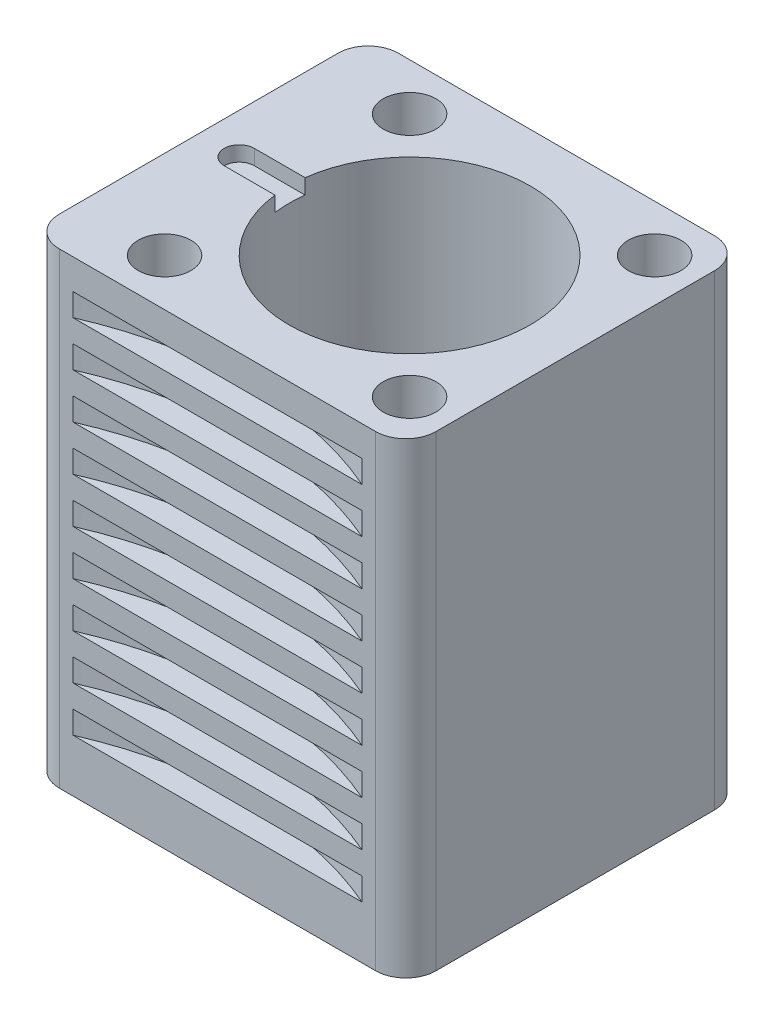
from build123d import *

# Parameters (mm, degrees)
BOSS_EXTRUDE1_DEPTH     = 62
SKETCH2_R               = 18
BOSS_EXTRUDE2_DEPTH     = 2
SKETCH3_R               = 16
CUT_EXTRUDE1_DEPTH      = 65
CUT_EXTRUDE2_DEPTH      = 2
SKETCH6_R               = 3.5
CUT_EXTRUDE3_DEPTH      = 65
SKETCH7_W               = 48
SKETCH7_H               = 3
LPATTERN1_COUNT         = 9
LPATTERN1_PITCH         = 6
MIRROR1_COPY_1_SKETCH_W = 48
MIRROR1_COPY_1_SKETCH_H = 3
MIRROR1_COPY_2_SKETCH_W = 48
MIRROR1_COPY_2_SKETCH_H = 3
MIRROR1_COPY_3_SKETCH_W = 48
MIRROR1_COPY_3_SKETCH_H = 3
MIRROR1_COPY_4_SKETCH_W = 48
MIRROR1_COPY_4_SKETCH_H = 3
MIRROR1_COPY_5_SKETCH_W = 48
MIRROR1_COPY_5_SKETCH_H = 3
MIRROR1_COPY_6_SKETCH_W = 48
MIRROR1_COPY_6_SKETCH_H = 3
MIRROR1_COPY_7_SKETCH_W = 48
MIRROR1_COPY_7_SKETCH_H = 3
MIRROR1_COPY_8_SKETCH_W = 48
MIRROR1_COPY_8_SKETCH_H = 3
SKETCH9_W               = 48
SKETCH9_H               = 3
LPATTERN2_COUNT         = 9
LPATTERN2_PITCH         = 6


with BuildPart() as part:
    # Sketch1 → Boss-Extrude1 (new body)
    with BuildSketch(Plane(origin=(0, 0, 0), x_dir=(1, 0, 0), z_dir=(0, 1, 0))):
        with BuildLine():
            Line((-24, 22.5), (18, 22.5))
            ThreePointArc((18, 22.5), (20.828427125, 21.328427125), (22, 18.5))
            Line((22, 18.5), (22, -18.5))
            ThreePointArc((22, -18.5), (20.828427125, -21.328427125), (18, -22.5))
            Line((18, -22.5), (-24, -22.5))
            ThreePointArc((-24, -22.5), (-26.828427125, -21.328427125), (-28, -18.5))
            Line((-28, -18.5), (-28, 18.5))
            ThreePointArc((-28, 18.5), (-26.828427125, 21.328427125), (-24, 22.5))
        make_face()
    extrude(amount=BOSS_EXTRUDE1_DEPTH)

    # Sketch2 → Boss-Extrude2 (add)
    with BuildSketch(Plane.XZ):
        Circle(SKETCH2_R)
    extrude(amount=BOSS_EXTRUDE2_DEPTH)

    # Sketch3 → Cut-Extrude1 (cut, through all)
    with BuildSketch(Plane.XZ.offset(2)):
        Circle(SKETCH3_R)
    extrude(amount=-CUT_EXTRUDE1_DEPTH, mode=Mode.SUBTRACT)

    # Sketch5 → Cut-Extrude2 (cut)
    with BuildSketch(Plane(origin=(0, 62, 0), x_dir=(1, 0, 0), z_dir=(0, 1, 0))):
        with BuildLine():
            Line((-22.61, 2), (-11.427293838, 2))
            Line((-11.427293838, 2), (-11.427293838, -2))
            Line((-11.427293838, -2), (-22.61, -2))
            ThreePointArc((-22.61, -2), (-24.61, 0), (-22.61, 2))
        make_face()
    extrude(amount=-CUT_EXTRUDE2_DEPTH, mode=Mode.SUBTRACT)

    # Sketch6 → Cut-Extrude3 (cut, through all)
    with BuildSketch(Plane(origin=(0, 62, 0), x_dir=(1, 0, 0), z_dir=(0, 1, 0))):
        with Locations((16.263455967, 16.263455967)):
            Circle(SKETCH6_R)
        with Locations((16.263455967, -16.263455967)):
            Circle(SKETCH6_R)
        with Locations((-16.263455967, -16.263455967)):
            Circle(SKETCH6_R)
        with Locations((-16.263455967, 16.263455967)):
            Circle(SKETCH6_R)
    extrude(amount=-CUT_EXTRUDE3_DEPTH, mode=Mode.SUBTRACT)

    # Sketch7 → Cut-Revolve1 (revolve, cut)
    with BuildSketch(Plane(origin=(-3, 0, 0), x_dir=(0, 0, -1), z_dir=(1, 0, 0))):
        with Locations((-42.5, 56.5)):
            Rectangle(SKETCH7_W, SKETCH7_H)
    cut_revolve1 = revolve(axis=Axis((-3, 58, 66.5), (0, -1, 0)), mode=Mode.SUBTRACT)

    # LPattern1: Cut-Revolve1 ×9
    with Locations(*[(0, -i * LPATTERN1_PITCH, 0) for i in range(1, LPATTERN1_COUNT)]):
        add(cut_revolve1, mode=Mode.SUBTRACT)

    # Mirror1: Cut-Revolve1 across plane
    add(cut_revolve1.mirror(Plane.XY), mode=Mode.SUBTRACT)

    # Mirror1 copy 1 sketch → Mirror1 copy 1 (revolve, cut)
    with BuildSketch(Plane(origin=(-3, -6, 0), x_dir=(0, 0, 1), z_dir=(1, 0, 0))):
        with Locations((-42.5, -56.5)):
            Rectangle(MIRROR1_COPY_1_SKETCH_W, MIRROR1_COPY_1_SKETCH_H)
    revolve(axis=Axis((-3, 52, -66.5), (0, 1, 0)), mode=Mode.SUBTRACT)

    # Mirror1 copy 2 sketch → Mirror1 copy 2 (revolve, cut)
    with BuildSketch(Plane(origin=(-3, -12, 0), x_dir=(0, 0, 1), z_dir=(1, 0, 0))):
        with Locations((-42.5, -56.5)):
            Rectangle(MIRROR1_COPY_2_SKETCH_W, MIRROR1_COPY_2_SKETCH_H)
    revolve(axis=Axis((-3, 46, -66.5), (0, 1, 0)), mode=Mode.SUBTRACT)

    # Mirror1 copy 3 sketch → Mirror1 copy 3 (revolve, cut)
    with BuildSketch(Plane(origin=(-3, -18, 0), x_dir=(0, 0, 1), z_dir=(1, 0, 0))):
        with Locations((-42.5, -56.5)):
            Rectangle(MIRROR1_COPY_3_SKETCH_W, MIRROR1_COPY_3_SKETCH_H)
    revolve(axis=Axis((-3, 40, -66.5), (0, 1, 0)), mode=Mode.SUBTRACT)

    # Mirror1 copy 4 sketch → Mirror1 copy 4 (revolve, cut)
    with BuildSketch(Plane(origin=(-3, -24, 0), x_dir=(0, 0, 1), z_dir=(1, 0, 0))):
        with Locations((-42.5, -56.5)):
            Rectangle(MIRROR1_COPY_4_SKETCH_W, MIRROR1_COPY_4_SKETCH_H)
    revolve(axis=Axis((-3, 34, -66.5), (0, 1, 0)), mode=Mode.SUBTRACT)

    # Mirror1 copy 5 sketch → Mirror1 copy 5 (revolve, cut)
    with BuildSketch(Plane(origin=(-3, -30, 0), x_dir=(0, 0, 1), z_dir=(1, 0, 0))):
        with Locations((-42.5, -56.5)):
            Rectangle(MIRROR1_COPY_5_SKETCH_W, MIRROR1_COPY_5_SKETCH_H)
    revolve(axis=Axis((-3, 28, -66.5), (0, 1, 0)), mode=Mode.SUBTRACT)

    # Mirror1 copy 6 sketch → Mirror1 copy 6 (revolve, cut)
    with BuildSketch(Plane(origin=(-3, -36, 0), x_dir=(0, 0, 1), z_dir=(1, 0, 0))):
        with Locations((-42.5, -56.5)):
            Rectangle(MIRROR1_COPY_6_SKETCH_W, MIRROR1_COPY_6_SKETCH_H)
    revolve(axis=Axis((-3, 22, -66.5), (0, 1, 0)), mode=Mode.SUBTRACT)

    # Mirror1 copy 7 sketch → Mirror1 copy 7 (revolve, cut)
    with BuildSketch(Plane(origin=(-3, -42, 0), x_dir=(0, 0, 1), z_dir=(1, 0, 0))):
        with Locations((-42.5, -56.5)):
            Rectangle(MIRROR1_COPY_7_SKETCH_W, MIRROR1_COPY_7_SKETCH_H)
    revolve(axis=Axis((-3, 16, -66.5), (0, 1, 0)), mode=Mode.SUBTRACT)

    # Mirror1 copy 8 sketch → Mirror1 copy 8 (revolve, cut)
    with BuildSketch(Plane(origin=(-3, -48, 0), x_dir=(0, 0, 1), z_dir=(1, 0, 0))):
        with Locations((-42.5, -56.5)):
            Rectangle(MIRROR1_COPY_8_SKETCH_W, MIRROR1_COPY_8_SKETCH_H)
    revolve(axis=Axis((-3, 10, -66.5), (0, 1, 0)), mode=Mode.SUBTRACT)

    # Sketch9 → Cut-Revolve3 (revolve, cut)
    with BuildSketch(Plane.XY):
        with Locations((-48, 56.5)):
            Rectangle(SKETCH9_W, SKETCH9_H)
    cut_revolve3 = revolve(axis=Axis((-72, 58, 0), (0, -1, 0)), mode=Mode.SUBTRACT)

    # LPattern2: Cut-Revolve3 ×9
    with Locations(*[(0, -i * LPATTERN2_PITCH, 0) for i in range(1, LPATTERN2_COUNT)]):
        add(cut_revolve3, mode=Mode.SUBTRACT)


solid = part.part
